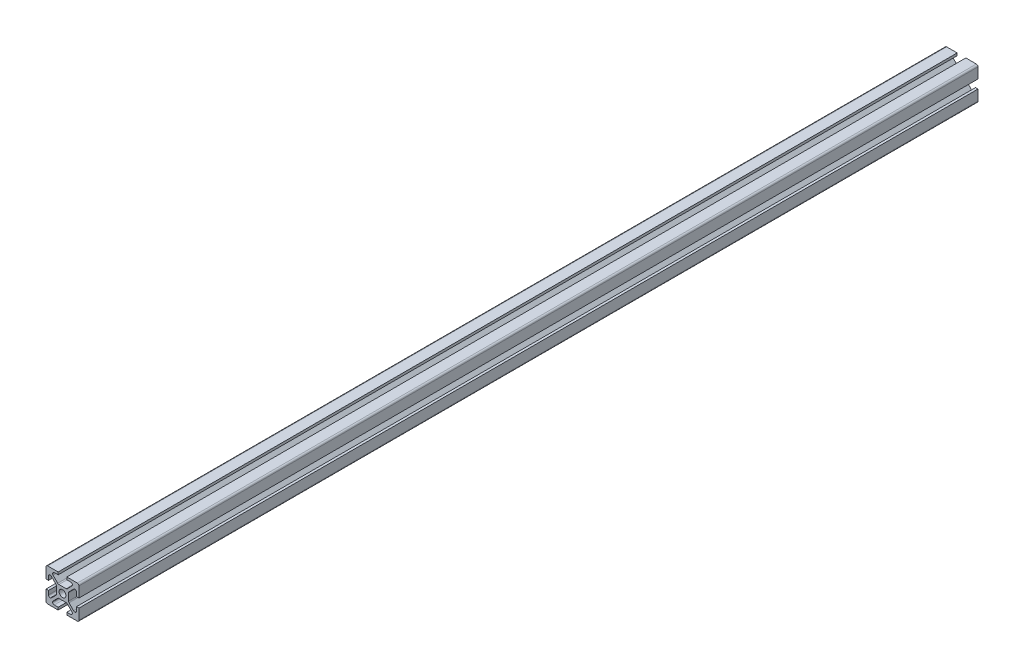
from build123d import *

# Parameters (mm, degrees)
SKETCH1_R           = 2.06
BOSS_EXTRUDE1_DEPTH = 272.5
CUT_EXTRUDE1_DEPTH  = 546
CIRPATTERN1_COUNT   = 4


with BuildPart() as part:
    # Sketch1 → Boss-Extrude1 (new body, symmetric)
    with BuildSketch(Plane.XY):
        with BuildLine():
            Line((-9, 10), (9, 10))
            ThreePointArc((9, 10), (9.707106781, 9.707106781), (10, 9))
            Line((10, 9), (10, -9))
            ThreePointArc((10, -9), (9.707106781, -9.707106781), (9, -10))
            Line((9, -10), (-9, -10))
            ThreePointArc((-9, -10), (-9.707106781, -9.707106781), (-10, -9))
            Line((-10, -9), (-10, 9))
            ThreePointArc((-10, 9), (-9.707106781, 9.707106781), (-9, 10))
        make_face()
        Circle(SKETCH1_R, mode=Mode.SUBTRACT)
    extrude(amount=BOSS_EXTRUDE1_DEPTH, both=True)

    # Sketch2 → Cut-Extrude1 (cut, through all)
    with BuildSketch(Plane(origin=(0, 0, -272.5), x_dir=(-1, 0, 0), z_dir=(0, 0, -1))):
        with BuildLine():
            Line((-10, 2.63), (-8.5, 2.63))
            Line((-8.5, 2.63), (-8.5, 4.995))
            ThreePointArc((-8.5, 4.995), (-8.207106781, 5.702106781), (-7.5, 5.995))
            Line((-7.5, 5.995), (-7.469873734, 5.995))
            ThreePointArc((-7.469873734, 5.995), (-7.087190302, 5.918879533), (-6.762766953, 5.702106781))
            Line((-6.762766953, 5.702106781), (-3.947893219, 2.887233047))
            ThreePointArc((-3.947893219, 2.887233047), (-3.731120467, 2.562809698), (-3.655, 2.180126266))
            Line((-3.655, 2.180126266), (-3.655, -2.180126266))
            ThreePointArc((-3.655, -2.180126266), (-3.731120467, -2.562809698), (-3.947893219, -2.887233047))
            Line((-3.947893219, -2.887233047), (-6.762766953, -5.702106781))
            ThreePointArc((-6.762766953, -5.702106781), (-7.087190302, -5.918879533), (-7.469873734, -5.995))
            Line((-7.469873734, -5.995), (-7.5, -5.995))
            ThreePointArc((-7.5, -5.995), (-8.207106781, -5.702106781), (-8.5, -4.995))
            Line((-8.5, -4.995), (-8.5, -2.63))
            Line((-8.5, -2.63), (-10, -2.63))
            Line((-10, -2.63), (-10, 2.63))
        make_face()
    cut_extrude1 = extrude(amount=-CUT_EXTRUDE1_DEPTH, mode=Mode.SUBTRACT)

    # CirPattern1: Cut-Extrude1 ×4 about axis
    cirpattern1_axis = Axis((0, 0, 0), (0, 0, 1))
    for i in range(1, CIRPATTERN1_COUNT):
        add(cut_extrude1.rotate(cirpattern1_axis, i * 360 / CIRPATTERN1_COUNT), mode=Mode.SUBTRACT)


solid = part.part
